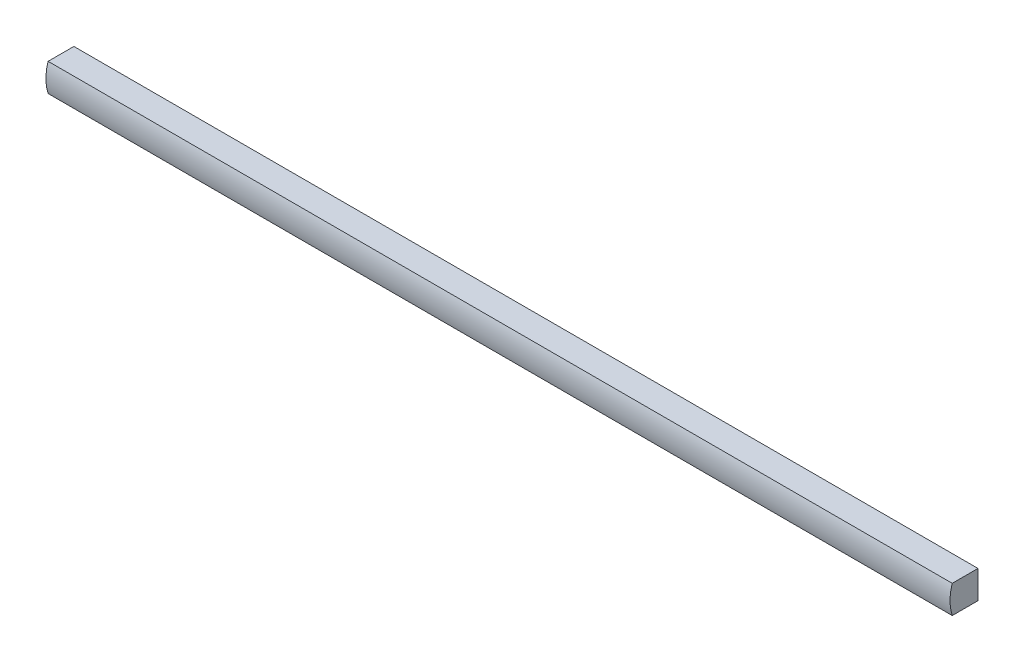
from build123d import *

# Parameters (mm, degrees)
BOSS_EXTRUDE1_DEPTH = 307.975


with BuildPart() as part:
    # Sketch1 → Boss-Extrude1 (new body)
    with BuildSketch(Plane(origin=(0, 0, 0), x_dir=(0, 0, -1), z_dir=(1, 0, 0))):
        with BuildLine():
            ThreePointArc((0, 4.782677505), (0.1900696, 2.361677335), (0.755621044, 0))
            Line((0.755621044, 0), (9.525, 0))
            Line((9.525, 0), (9.525, 9.525))
            Line((9.525, 9.525), (0.742604052, 9.525))
            ThreePointArc((0.742604052, 9.525), (0.186775343, 7.182733932), (0, 4.782677505))
        make_face()
    extrude(amount=-BOSS_EXTRUDE1_DEPTH)


solid = part.part
